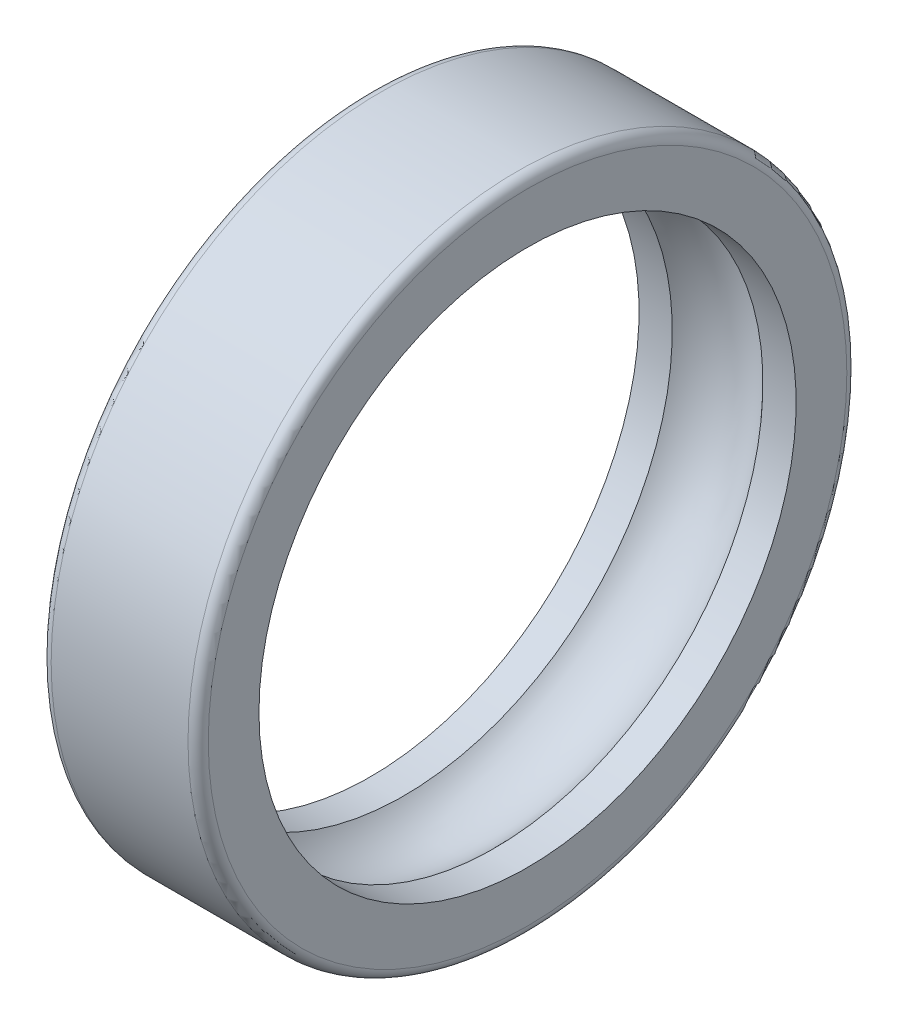
from build123d import *

# Parameters (mm, degrees)
FILLET1_R = 2


with BuildPart() as part:
    # Sketch1 → Revolve1 (revolve)
    with BuildSketch(Plane.XY):
        with BuildLine():
            Line((15.5, 65), (-15.5, 65))
            Line((-15.5, 65), (-15.5, 53))
            Line((-15.5, 53), (-8.94427191, 53))
            ThreePointArc((-8.94427191, 53), (0, 57), (8.94427191, 53))
            Line((8.94427191, 53), (15.5, 53))
            Line((15.5, 53), (15.5, 65))
        make_face()
    revolve(axis=Axis((-15.5, 0, 0), (1, 0, 0)))

    # Fillet1
    fillet1_edges = [part.edges().sort_by_distance(p)[0] for p in [
        (15.5, -65, 0),
        (-15.5, -65, 0),
    ]]
    fillet(fillet1_edges, radius=FILLET1_R)


solid = part.part
